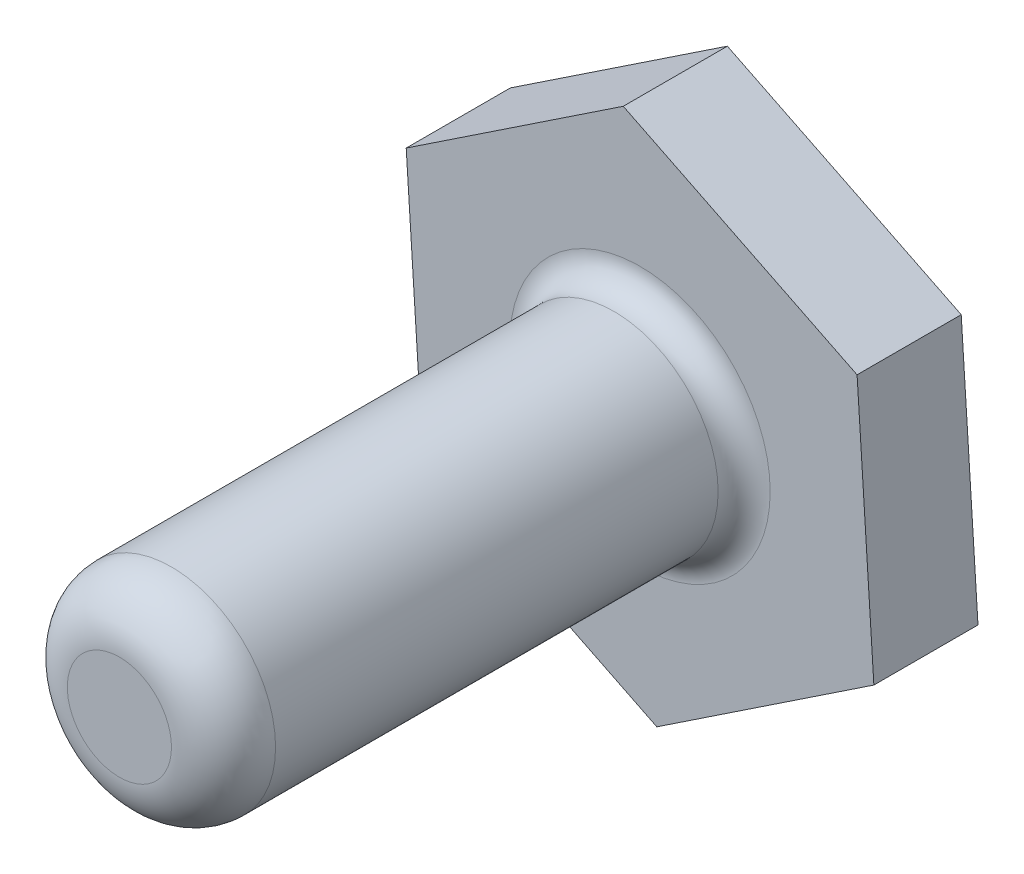
from build123d import *

# Parameters (mm, degrees)
EXTRUDE_3_DEPTH = 4
SKETCH_3_R      = 4
EXTRUDE_4_DEPTH = 20
FILLET_1_R      = 1
FILLET_2_R      = 2


with BuildPart() as part:
    # 草图1 → 凸台-拉伸3 (new body)
    with BuildSketch(Plane.XY):
        Polygon((-8.337851922, -5.558416845), (0.644804231, -10), (8.982656153, -4.441583155), (8.337851922, 5.558416845), (-0.644804231, 10), (-8.982656153, 4.441583155), align=None)
    extrude(amount=EXTRUDE_3_DEPTH)

    # 草图3 → 凸台-拉伸4 (add)
    with BuildSketch(Plane.XY.offset(4)):
        Circle(SKETCH_3_R)
    extrude(amount=EXTRUDE_4_DEPTH)

    # 圆角1
    fillet_1_edges = [part.edges().sort_by_distance(p)[0] for p in [
        (-4, 0, 4),
    ]]
    fillet(fillet_1_edges, radius=FILLET_1_R)

    # 圆角2
    fillet_2_edges = [part.edges().sort_by_distance(p)[0] for p in [
        (-4, 0, 24),
    ]]
    fillet(fillet_2_edges, radius=FILLET_2_R)


solid = part.part
